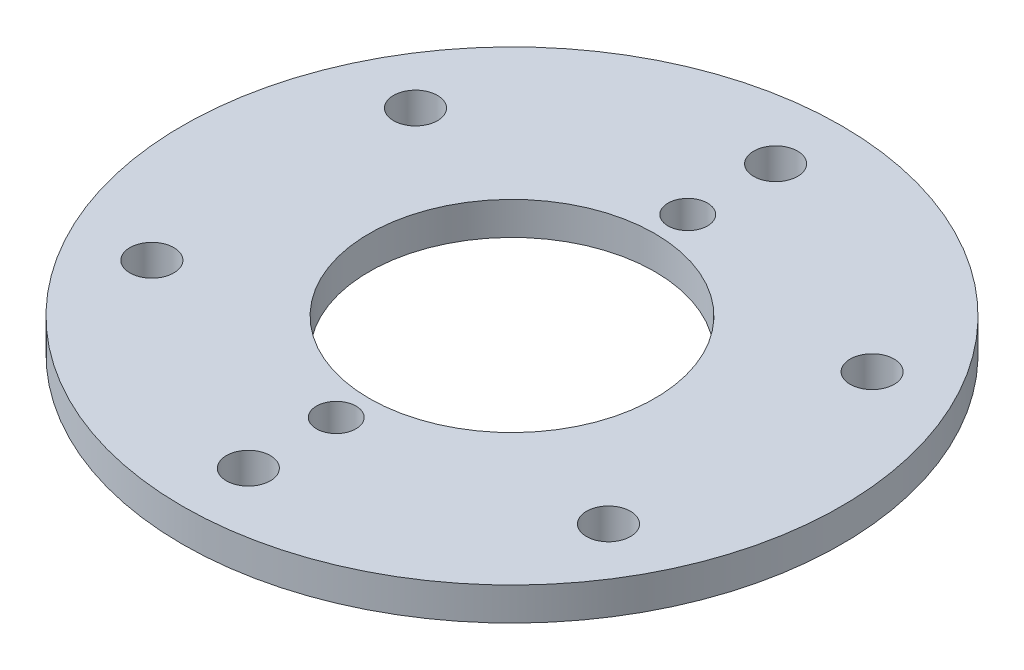
from build123d import *

# Parameters (mm, degrees)
SKETCH2_R                    = 150
SKETCH2_R_2                  = 65
BOSS_EXTRUDE1_DEPTH          = 15
TAP_DRILL_FOR_M14X2_0_TAP1_D = 20
CIRPATTERN1_COUNT            = 6
TAP_DRILL_FOR_M14X2_0_TAP2_D = 18
CIRPATTERN2_COUNT            = 2


with BuildPart() as part:
    # Sketch2 → Boss-Extrude1 (new body)
    with BuildSketch(Plane(origin=(0, 0, 0), x_dir=(1, 0, 0), z_dir=(0, 1, 0))):
        Circle(SKETCH2_R)
        Circle(SKETCH2_R_2, mode=Mode.SUBTRACT)
    extrude(amount=BOSS_EXTRUDE1_DEPTH)

    # Tap Drill for M14x2.0 Tap1 (through all)
    with Locations(Plane(origin=(0, 15, 0), x_dir=(1, 0, 0), z_dir=(0, 1, 0))):
        with Locations((0, 120)):
            tap_drill_for_m14x2_0_tap1 = Hole(TAP_DRILL_FOR_M14X2_0_TAP1_D / 2)

    # CirPattern1: Tap Drill for M14x2.0 Tap1 ×6 about axis
    cirpattern1_axis = Axis((0, -0.75, 0), (0, 1, 0))
    for i in range(1, CIRPATTERN1_COUNT):
        add(tap_drill_for_m14x2_0_tap1.rotate(cirpattern1_axis, i * 360 / CIRPATTERN1_COUNT), mode=Mode.SUBTRACT)

    # Tap Drill for M14x2.0 Tap2 (through all)
    with Locations(Plane(origin=(0, 15, 0), x_dir=(1, 0, 0), z_dir=(0, 1, 0))):
        with Locations((0, 80)):
            tap_drill_for_m14x2_0_tap2 = Hole(TAP_DRILL_FOR_M14X2_0_TAP2_D / 2)

    # CirPattern2: Tap Drill for M14x2.0 Tap2 ×2 about axis
    cirpattern2_axis = Axis((0, -0.75, 0), (0, 1, 0))
    for i in range(1, CIRPATTERN2_COUNT):
        add(tap_drill_for_m14x2_0_tap2.rotate(cirpattern2_axis, i * 360 / CIRPATTERN2_COUNT), mode=Mode.SUBTRACT)


solid = part.part
